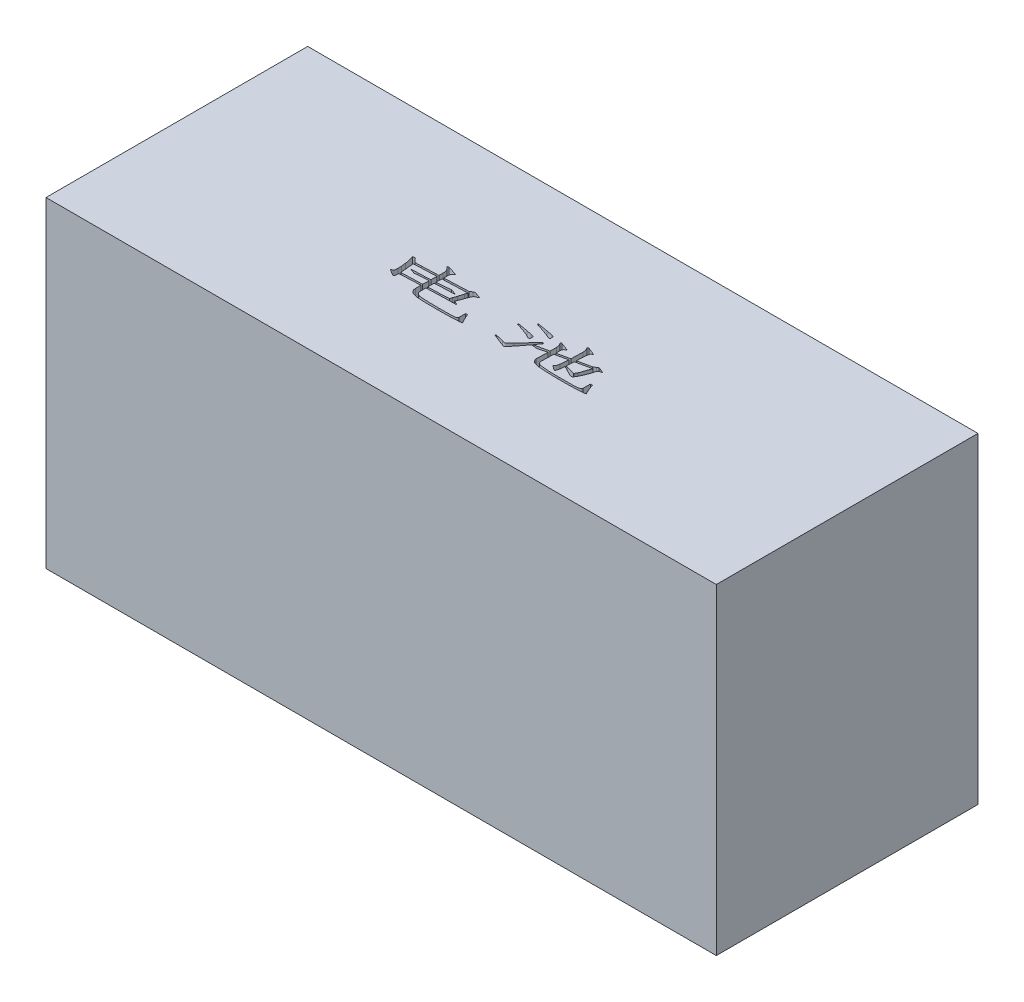
from build123d import *

# Parameters (mm, degrees)
SKETCH_1_W          = 73
SKETCH_1_H          = 28.5
EXTRUDE_1_DEPTH     = 35
CUT_EXTRUDE_1_DEPTH = 35


with BuildPart() as part:
    # 草图1 → 凸台-拉伸1 (new body)
    with BuildSketch(Plane(origin=(0, 0, 0), x_dir=(1, 0, 0), z_dir=(0, 1, 0))):
        Rectangle(SKETCH_1_W, SKETCH_1_H)
    extrude(amount=EXTRUDE_1_DEPTH)

    # 草图2 → 切除-拉伸1 (cut)
    with BuildSketch(Plane(origin=(0, 35, 0), x_dir=(1, 0, 0), z_dir=(0, 1, 0))):
        with BuildLine():
            Line((-10.707010031, 0.172814835), (-10.472085676, -0.074042186))
            Line((-10.472085676, -0.074042186), (-10.274450901, -0.290321751))
            Line((-10.274450901, -0.290321751), (-9.589068416, -0.270185378))
            Line((-9.589068416, -0.270185378), (-8.147453245, -0.22021734))
            Line((-8.147453245, -0.22021734), (-7.768591109, -0.200080967))
            Line((-7.768591109, -0.200080967), (-7.750692111, 0.26305562))
            add(Edge.make_bspline(
                [(-7.750692111, 0.26305562), (-7.750946332, 0.267032809), (-7.751740654, 0.279459649), (-7.753025791, 0.304847147), (-7.756515725, 0.343575859), (-7.759279045, 0.395227709), (-7.767268447, 0.458301711), (-7.784164071, 0.530582258), (-7.809571783, 0.610931523), (-7.840129127, 0.699888406), (-7.886137896, 0.793301523), (-7.953907193, 0.885469326), (-8.042517838, 0.97509931), (-8.111279609, 1.029956458), (-8.147453245, 1.058815262)],
                knots=[0, 0, 0, 0, 1.1956e-05, 3.7357e-05, 7.6252e-05, 0.000128591, 0.000192512, 0.000266691, 0.000350912, 0.000445278, 0.000548672, 0.000661899, 0.000786892, 0.000925638, 0.000925638, 0.000925638, 0.000925638], degree=3))
            Line((-8.147453245, 1.058815262), (-7.984870675, 1.128919672))
            Line((-7.984870675, 1.128919672), (-6.903472848, 0.786601326))
            add(Edge.make_bspline(
                [(-6.903472848, 0.786601326), (-6.931834624, 0.769628061), (-6.985546709, 0.737483762), (-7.057652231, 0.685317312), (-7.116950825, 0.632779809), (-7.167169144, 0.579718346), (-7.20418339, 0.516037304), (-7.228927556, 0.438914232), (-7.24315952, 0.346111903), (-7.244870519, 0.279020578), (-7.245791195, 0.242919246)],
                knots=[0, 0, 0, 0, 9.9134e-05, 0.000187742, 0.000266461, 0.000336696, 0.000405895, 0.000485373, 0.00057831, 0.000686576, 0.000686576, 0.000686576, 0.000686576], degree=3))
            Line((-7.245791195, 0.242919246), (-7.245791195, -0.179944594))
            Line((-7.245791195, -0.179944594), (-6.362773935, -0.149367138))
            Line((-6.362773935, -0.149367138), (-4.974855759, -0.094178559))
            Line((-4.974855759, -0.094178559), (-4.632537412, -0.074042186))
            Line((-4.632537412, -0.074042186), (-4.326017063, 0.101964633))
            add(Edge.make_bspline(
                [(-4.326017063, 0.101964633), (-4.312276138, 0.110511209), (-4.287564854, 0.125881123), (-4.252224004, 0.141964842), (-4.224372566, 0.153184803), (-4.198837208, 0.156140624), (-4.170498908, 0.150121653), (-4.132191241, 0.142367413), (-4.080207855, 0.129251154), (-4.041342455, 0.118467224), (-4.019496714, 0.112405715)],
                knots=[0, 0, 0, 0, 4.8476e-05, 8.7179e-05, 0.000116427, 0.00013817, 0.000163062, 0.000202701, 0.0002557, 0.000323726, 0.000323726, 0.000323726, 0.000323726], degree=3))
            Line((-4.019496714, 0.112405715), (-3.586937583, -0.023328357))
            add(Edge.make_bspline(
                [(-3.586937583, -0.023328357), (-3.565819521, -0.030856203), (-3.529671102, -0.043741843), (-3.486996326, -0.064583138), (-3.458745983, -0.07787574), (-3.448056382, -0.100791354), (-3.466420677, -0.119441528), (-3.482788373, -0.13020789), (-3.499581218, -0.136655745), (-3.513692103, -0.143487747), (-3.533355506, -0.151348532), (-3.557497147, -0.162287407), (-3.587223716, -0.174638146), (-3.62188487, -0.189637629), (-3.661925383, -0.205928125), (-3.720056634, -0.230970062), (-3.791534576, -0.266272744), (-3.865322001, -0.32259385), (-3.925569577, -0.388669809), (-3.952432657, -0.440525296), (-3.965799718, -0.46632857)],
                knots=[0, 0, 0, 0, 6.7038e-05, 0.000114752, 0.000143713, 0.000158116, 0.000182317, 0.000209831, 0.000219526, 0.000235883, 0.000256937, 0.000282987, 0.000315401, 0.000353495, 0.000396292, 0.00044506, 0.000543465, 0.000634454, 0.000722154, 0.000809015, 0.000809015, 0.000809015, 0.000809015], degree=3))
            Line((-3.965799718, -0.46632857), (-4.164180285, -0.989874276))
            Line((-4.164180285, -0.989874276), (-4.398358849, -1.629763473))
            Line((-4.398358849, -1.629763473), (-4.470700634, -1.790854459))
            Line((-4.470700634, -1.790854459), (-4.127636496, -1.926588531))
            add(Edge.make_bspline(
                [(-4.127636496, -1.926588531), (-4.114561488, -1.93255981), (-4.091925661, -1.942897458), (-4.065037692, -1.958708582), (-4.048465089, -1.972141284), (-4.045052084, -1.987979913), (-4.05662412, -1.998042665), (-4.073735953, -2.002781165), (-4.098187706, -2.00648772), (-4.116937191, -2.00689921), (-4.127636496, -2.007134025)],
                knots=[0, 0, 0, 0, 4.303e-05, 7.4495e-05, 9.4015e-05, 0.0001053, 0.000117441, 0.0001349, 0.000159054, 0.000191158, 0.000191158, 0.000191158, 0.000191158], degree=3))
            Line((-4.127636496, -2.007134025), (-4.416257847, -2.012354566))
            Line((-4.416257847, -2.012354566), (-6.00255659, -2.052627312))
            Line((-6.00255659, -2.052627312), (-6.903472848, -2.082458977))
            Line((-6.903472848, -2.082458977), (-7.282334983, -2.097374809))
            Line((-7.282334983, -2.097374809), (-7.282334983, -2.641056888))
            add(Edge.make_bspline(
                [(-7.282334983, -2.641056888), (-7.281712187, -2.669194737), (-7.280482796, -2.724738443), (-7.267858653, -2.806625852), (-7.248674378, -2.885635131), (-7.226268402, -2.949739619), (-7.201026783, -2.998484418), (-7.1752533, -3.033348861), (-7.142271328, -3.065219324), (-7.104392939, -3.096931214), (-7.059157535, -3.125863564), (-7.00730282, -3.152614307), (-6.949068204, -3.17750803), (-6.895039502, -3.198448984), (-6.842328724, -3.213364248), (-6.788977049, -3.222035959), (-6.723657429, -3.231964262), (-6.645526715, -3.240688539), (-6.554762063, -3.248755044), (-6.45107493, -3.256112904), (-6.334718312, -3.262747724), (-6.205686431, -3.268650719), (-6.064227124, -3.273805291), (-5.910092187, -3.278246564), (-5.743279982, -3.2819988), (-5.563533515, -3.284621093), (-5.371379933, -3.288192145), (-5.166522644, -3.288968703), (-4.94900521, -3.291099756), (-4.799595362, -3.290797023), (-4.722778197, -3.290641376)],
                knots=[0, 0, 0, 0, 8.4357e-05, 0.000166519, 0.000247917, 0.000328137, 0.000369506, 0.000412167, 0.000457519, 0.000506792, 0.000560162, 0.000618205, 0.000681663, 0.000750097, 0.000791894, 0.000845726, 0.000912068, 0.000990145, 0.0010815, 0.001185433, 0.00130197, 0.00143113, 0.001572927, 0.001726625, 0.001893724, 0.002073484, 0.002265922, 0.002470274, 0.00268805, 0.0029185, 0.0029185, 0.0029185, 0.0029185], degree=3))
            add(Edge.make_bspline(
                [(-4.722778197, -3.290641376), (-4.650685026, -3.290624858), (-4.510724837, -3.29059279), (-4.307371591, -3.29081756), (-4.116944412, -3.290045087), (-3.939691979, -3.288610468), (-3.775367134, -3.286370264), (-3.624212855, -3.28353304), (-3.486253, -3.279553938), (-3.36143854, -3.276106569), (-3.249809397, -3.271670735), (-3.151100145, -3.266536385), (-3.065564026, -3.260676959), (-2.992912065, -3.254240211), (-2.933530925, -3.246606071), (-2.886975776, -3.239999826), (-2.853641358, -3.231527096), (-2.817284475, -3.215765537), (-2.783066491, -3.18358237), (-2.744012413, -3.145175026), (-2.717490434, -3.103152074), (-2.708315662, -3.073602319), (-2.703920323, -3.059445979)],
                knots=[0, 0, 0, 0, 0.00021628, 0.000419881, 0.000610059, 0.000787564, 0.000951653, 0.001103078, 0.0012411, 0.001365703, 0.001477661, 0.001576244, 0.001662217, 0.00173487, 0.001794997, 0.001841834, 0.001875847, 0.001897883, 0.001959963, 0.002014304, 0.002062527, 0.002106875, 0.002106875, 0.002106875, 0.002106875], degree=3))
            Line((-2.703920323, -3.059445979), (-2.703920323, -2.782011502))
            Line((-2.703920323, -2.782011502), (-2.703920323, -2.34423183))
            Line((-2.703920323, -2.34423183), (-2.487640758, -2.334536539))
            Line((-2.487640758, -2.334536539), (-2.451842761, -2.455354779))
            Line((-2.451842761, -2.455354779), (-2.361601977, -2.661193262))
            Line((-2.361601977, -2.661193262), (-2.235563196, -2.933407197))
            Line((-2.235563196, -2.933407197), (-2.109524414, -3.164602595))
            Line((-2.109524414, -3.164602595), (-2.01928363, -3.330914123))
            add(Edge.make_bspline(
                [(-2.01928363, -3.330914123), (-2.014073457, -3.33847371), (-2.004876227, -3.351818229), (-1.995762729, -3.371061967), (-1.993834404, -3.387815847), (-2.001096318, -3.401383097), (-2.017089527, -3.409349998), (-2.04014304, -3.415349666), (-2.071745474, -3.422216676), (-2.096064627, -3.424893771), (-2.109524414, -3.426375448)],
                knots=[0, 0, 0, 0, 2.7514e-05, 4.8568e-05, 6.3503e-05, 7.6181e-05, 9.1914e-05, 0.000115272, 0.000148036, 0.000188646, 0.000188646, 0.000188646, 0.000188646], degree=3))
            Line((-2.109524414, -3.426375448), (-2.253462194, -3.442037072))
            add(Edge.make_bspline(
                [(-2.253462194, -3.442037072), (-2.270357116, -3.44388718), (-2.311287804, -3.448369368), (-2.38347487, -3.452841999), (-2.476903907, -3.459226388), (-2.59155602, -3.464655702), (-2.727259472, -3.471737826), (-2.883907607, -3.478026538), (-3.061631221, -3.485801095), (-3.32513051, -3.495498705), (-3.664195186, -3.50618358), (-4.068194747, -3.513951955), (-4.461987451, -3.519295523), (-4.721036677, -3.518000711), (-4.848816978, -3.517362024)],
                knots=[0, 0, 0, 0, 5.0982e-05, 0.000123512, 0.000216926, 0.000331933, 0.000467833, 0.000624593, 0.000802248, 0.001001514, 0.001415623, 0.001819925, 0.002213728, 0.002597066, 0.002597066, 0.002597066, 0.002597066], degree=3))
            add(Edge.make_bspline(
                [(-4.848816978, -3.517362024), (-4.922152784, -3.51707093), (-5.0650955, -3.516503543), (-5.273926122, -3.51638225), (-5.471798937, -3.513447035), (-5.658765019, -3.511987091), (-5.834749985, -3.507534253), (-5.999606612, -3.504597619), (-6.153451522, -3.498641284), (-6.296453409, -3.494242082), (-6.428403842, -3.48681911), (-6.549311942, -3.480939388), (-6.659109656, -3.472003494), (-6.758193042, -3.464703187), (-6.846329856, -3.454295129), (-6.923621979, -3.445572272), (-6.989647317, -3.433937062), (-7.061770439, -3.419610852), (-7.140493923, -3.399064891), (-7.226614829, -3.374427118), (-7.304992348, -3.350910983), (-7.374384328, -3.326093777), (-7.436173643, -3.303031191), (-7.488360757, -3.27762084), (-7.533648479, -3.254821903), (-7.580742603, -3.221956128), (-7.629386399, -3.178056176), (-7.679884895, -3.122509095), (-7.720782744, -3.061612237), (-7.752994601, -2.99691538), (-7.77537363, -2.928247077), (-7.793100337, -2.858340254), (-7.80266761, -2.785752331), (-7.804303476, -2.736791307), (-7.805134898, -2.711907091)],
                knots=[0, 0, 0, 0, 0.00022001, 0.000428833, 0.00062648, 0.000813687, 0.000989734, 0.001154596, 0.001308317, 0.001451605, 0.00158378, 0.001704785, 0.001814723, 0.001914252, 0.002002787, 0.002080953, 0.00214753, 0.002203841, 0.002301517, 0.002391461, 0.002472612, 0.002546911, 0.002612557, 0.002670273, 0.002720987, 0.002764429, 0.002842095, 0.002917098, 0.002989082, 0.003061458, 0.003133155, 0.003205327, 0.003277577, 0.003352249, 0.003352249, 0.003352249, 0.003352249], degree=3))
            Line((-7.805134898, -2.711907091), (-7.805134898, -2.117511182))
            Line((-7.805134898, -2.117511182), (-8.345833811, -2.133172806))
            Line((-8.345833811, -2.133172806), (-9.643511203, -2.188361384))
            Line((-9.643511203, -2.188361384), (-10.111868331, -2.208497758))
            Line((-10.111868331, -2.208497758), (-10.129767329, -2.435218406))
            Line((-10.129767329, -2.435218406), (-10.147666328, -2.565731936))
            add(Edge.make_bspline(
                [(-10.147666328, -2.565731936), (-10.148373549, -2.575534743), (-10.149822378, -2.595617007), (-10.162513707, -2.624623376), (-10.183825692, -2.650761677), (-10.210315824, -2.675829037), (-10.247628559, -2.693479544), (-10.294346757, -2.689193308), (-10.346832569, -2.6710928), (-10.381296365, -2.64892671), (-10.400489682, -2.636582139)],
                knots=[0, 0, 0, 0, 2.9324e-05, 6.0074e-05, 9.3041e-05, 0.000130016, 0.00016909, 0.000212371, 0.000266615, 0.000334792, 0.000334792, 0.000334792, 0.000334792], degree=3))
            Line((-10.400489682, -2.636582139), (-10.670466243, -2.46505007))
            Line((-10.670466243, -2.46505007), (-10.850947811, -2.354672912))
            add(Edge.make_bspline(
                [(-10.850947811, -2.354672912), (-10.861620335, -2.348544732), (-10.880685778, -2.337597325), (-10.905802657, -2.322213569), (-10.920983257, -2.310305381), (-10.933376673, -2.302136055), (-10.931412472, -2.292524412), (-10.925171985, -2.284321069), (-10.913878408, -2.273208669), (-10.896211537, -2.260492458), (-10.875091089, -2.24286569), (-10.84790809, -2.223504508), (-10.814773607, -2.202228696), (-10.791253181, -2.186420512), (-10.778606025, -2.177920302)],
                knots=[0, 0, 0, 0, 3.7095e-05, 6.6267e-05, 8.6555e-05, 9.8695e-05, 0.000103969, 0.000113693, 0.000129513, 0.000151295, 0.000178899, 0.000212018, 0.000251319, 0.000297032, 0.000297032, 0.000297032, 0.000297032], degree=3))
            add(Edge.make_bspline(
                [(-10.778606025, -2.177920302), (-10.764696744, -2.169096688), (-10.738104655, -2.152227497), (-10.70673111, -2.117273553), (-10.686963945, -2.07573381), (-10.676055125, -2.014991012), (-10.671670307, -1.941394984), (-10.662109879, -1.861728044), (-10.654580094, -1.797695649), (-10.65315095, -1.760537635), (-10.652567244, -1.745361171)],
                knots=[0, 0, 0, 0, 4.9245e-05, 9.4147e-05, 0.000138845, 0.00018536, 0.00027827, 0.000360053, 0.000426025, 0.000471573, 0.000471573, 0.000471573, 0.000471573], degree=3))
            Line((-10.652567244, -1.745361171), (-10.670466243, -1.36799062))
            Line((-10.670466243, -1.36799062), (-10.72490903, -0.894412951))
            add(Edge.make_bspline(
                [(-10.72490903, -0.894412951), (-10.725103309, -0.888443533), (-10.72556559, -0.874239464), (-10.727927251, -0.850106983), (-10.732010046, -0.820102303), (-10.735941368, -0.784155225), (-10.743478027, -0.742336375), (-10.750089791, -0.694139427), (-10.760543403, -0.640403629), (-10.773597049, -0.563730603), (-10.789527395, -0.472550117), (-10.809564087, -0.375569558), (-10.824973616, -0.297414883), (-10.838899721, -0.242849123), (-10.850646081, -0.203467756), (-10.86130471, -0.170470822), (-10.873726357, -0.131765678), (-10.889450857, -0.087767352), (-10.90861169, -0.038674079), (-10.928309666, 0.016862102), (-10.951451971, 0.077767616), (-10.968231832, 0.120133379), (-10.976986592, 0.14223738)],
                knots=[0, 0, 0, 0, 1.7915e-05, 4.2627e-05, 7.2691e-05, 0.000108768, 0.000151068, 0.000200115, 0.00025468, 0.00031525, 0.000433453, 0.000532325, 0.000612334, 0.000672388, 0.000701176, 0.000735611, 0.000776412, 0.000823118, 0.000875753, 0.000934501, 0.00099988, 0.001071204, 0.001071204, 0.001071204, 0.001071204], degree=3))
            Line((-10.976986592, 0.14223738), (-10.707010031, 0.172814835))
        make_face()
        with BuildLine():
            Line((-10.111868331, -2.001913483), (-7.805134898, -1.926588531))
            Line((-7.805134898, -1.926588531), (-7.786490108, -1.227036006))
            Line((-7.786490108, -1.227036006), (-8.273492026, -1.25686767))
            Line((-8.273492026, -1.25686767), (-8.832089938, -1.297140417))
            Line((-8.832089938, -1.297140417), (-9.336990854, -1.347854246))
            Line((-9.336990854, -1.347854246), (-9.463029635, -1.297140417))
            Line((-9.463029635, -1.297140417), (-9.769549984, -1.18676326))
            add(Edge.make_bspline(
                [(-9.769549984, -1.18676326), (-9.780119942, -1.183733244), (-9.798013612, -1.178603791), (-9.818957767, -1.170039314), (-9.832519852, -1.162080217), (-9.834339078, -1.149551264), (-9.821805188, -1.142814364), (-9.805796003, -1.137220671), (-9.781025213, -1.133030621), (-9.762317398, -1.131628385), (-9.751650986, -1.130828889)],
                knots=[0, 0, 0, 0, 3.2789e-05, 5.5509e-05, 6.926e-05, 7.6755e-05, 8.8405e-05, 0.000105864, 0.000130145, 0.000162352, 0.000162352, 0.000162352, 0.000162352], degree=3))
            Line((-9.751650986, -1.130828889), (-9.120711288, -1.106217766))
            Line((-9.120711288, -1.106217766), (-8.381631808, -1.080860852))
            Line((-8.381631808, -1.080860852), (-7.786490108, -1.050283396))
            Line((-7.786490108, -1.050283396), (-7.768591109, -0.396224159))
            Line((-7.768591109, -0.396224159), (-8.309290023, -0.421581073))
            Line((-8.309290023, -0.421581073), (-9.517472422, -0.46632857))
            Line((-9.517472422, -0.46632857), (-10.255806111, -0.502126567))
            Line((-10.255806111, -0.502126567), (-10.220008114, -0.894412951))
            Line((-10.220008114, -0.894412951), (-10.111868331, -2.001913483))
        make_face(mode=Mode.SUBTRACT)
        with BuildLine():
            Line((-7.282334983, -1.906452158), (-5.984657591, -1.866179411))
            Line((-5.984657591, -1.866179411), (-5.371616893, -1.835601956))
            Line((-5.371616893, -1.835601956), (-5.011399548, -1.815465582))
            Line((-5.011399548, -1.815465582), (-4.921158763, -1.573829102))
            Line((-4.921158763, -1.573829102), (-4.776475192, -1.166626886))
            Line((-4.776475192, -1.166626886), (-4.596739415, -0.552094604))
            Line((-4.596739415, -0.552094604), (-4.506498631, -0.28510121))
            Line((-4.506498631, -0.28510121), (-5.353717894, -0.310458124))
            Line((-5.353717894, -0.310458124), (-7.264435985, -0.381308327))
            Line((-7.264435985, -0.381308327), (-7.282334983, -1.020451732))
            add(Edge.make_bspline(
                [(-7.282334983, -1.020451732), (-7.193826599, -1.01459541), (-7.023243535, -1.003308464), (-6.776894793, -0.98522874), (-6.549848022, -0.967915726), (-6.342116616, -0.948622491), (-6.15330784, -0.931412778), (-5.983788856, -0.912629248), (-5.833327018, -0.894290648), (-5.739767666, -0.880651688), (-5.696036241, -0.874276577)],
                knots=[0, 0, 0, 0, 0.000266104, 0.000512866, 0.000741035, 0.000949202, 0.001138734, 0.001309794, 0.001460853, 0.00159343, 0.00159343, 0.00159343, 0.00159343], degree=3))
            Line((-5.696036241, -0.874276577), (-5.209034323, -1.040588105))
            add(Edge.make_bspline(
                [(-5.209034323, -1.040588105), (-5.195830636, -1.04559496), (-5.173082001, -1.054221272), (-5.147339182, -1.070392742), (-5.129344127, -1.082580681), (-5.126179873, -1.100047972), (-5.140080158, -1.110800748), (-5.160506194, -1.1162963), (-5.190769729, -1.120711124), (-5.214250265, -1.120979888), (-5.227679113, -1.121133598)],
                knots=[0, 0, 0, 0, 4.2109e-05, 7.255e-05, 9.2069e-05, 0.000104835, 0.000118546, 0.000139066, 0.000169231, 0.000209531, 0.000209531, 0.000209531, 0.000209531], degree=3))
            Line((-5.227679113, -1.121133598), (-5.479756675, -1.12635414))
            Line((-5.479756675, -1.12635414), (-6.074152584, -1.146490513))
            Line((-6.074152584, -1.146490513), (-6.651395286, -1.166626886))
            Line((-6.651395286, -1.166626886), (-7.282334983, -1.201679092))
            Line((-7.282334983, -1.201679092), (-7.282334983, -1.906452158))
        make_face(mode=Mode.SUBTRACT)
        with BuildLine():
            Line((4.193160435, -0.88471766), (4.409440001, -0.914549324))
            Line((4.409440001, -0.914549324), (4.301300218, -1.060724478))
            Line((4.301300218, -1.060724478), (3.904539084, -1.609627099))
            Line((3.904539084, -1.609627099), (5.43639504, -1.287445126))
            Line((5.43639504, -1.287445126), (5.43639504, -0.572230977))
            add(Edge.make_bspline(
                [(5.43639504, -0.572230977), (5.433082561, -0.534403858), (5.426849939, -0.463229944), (5.411877363, -0.363826219), (5.390837595, -0.279157838), (5.366410389, -0.205602734), (5.331798698, -0.140647118), (5.288035179, -0.078728734), (5.232061633, -0.018937375), (5.188931846, 0.017868449), (5.166418479, 0.037080763)],
                knots=[0, 0, 0, 0, 0.000113911, 0.00021433, 0.000301153, 0.000375452, 0.000446173, 0.000521079, 0.000602353, 0.000691106, 0.000691106, 0.000691106, 0.000691106], degree=3))
            Line((5.166418479, 0.037080763), (5.328255257, 0.097489883))
            Line((5.328255257, 0.097489883), (6.247816306, -0.264964836))
            add(Edge.make_bspline(
                [(6.247816306, -0.264964836), (6.220304983, -0.283115816), (6.169510223, -0.316628368), (6.102218033, -0.365993724), (6.050643486, -0.410516742), (6.013819606, -0.451011287), (5.989370241, -0.488852336), (5.969967291, -0.523117208), (5.957186538, -0.556897622), (5.947331675, -0.601402637), (5.941156998, -0.660322016), (5.933941134, -0.719320072), (5.928611546, -0.765413241), (5.929869615, -0.789680292), (5.930928744, -0.808316429), (5.938485568, -0.812362661), (5.941295956, -0.813867457)],
                knots=[0, 0, 0, 0, 9.8873e-05, 0.000182551, 0.000250184, 0.000303015, 0.000346038, 0.000385084, 0.00042096, 0.000453884, 0.0005216, 0.000598195, 0.000633374, 0.000658742, 0.000674117, 0.00068322, 0.00068322, 0.00068322, 0.00068322], degree=3))
            Line((5.941295956, -0.813867457), (5.941295956, -1.171101636))
            Line((5.941295956, -1.171101636), (7.293416135, -0.879497119))
            Line((7.293416135, -0.879497119), (7.329214132, 0.38387386))
            add(Edge.make_bspline(
                [(7.329214132, 0.38387386), (7.329172439, 0.392821906), (7.329054306, 0.418174703), (7.330394066, 0.45656499), (7.325252968, 0.504457796), (7.315269599, 0.559799189), (7.297442288, 0.631257576), (7.274843583, 0.714306074), (7.250237827, 0.798548595), (7.223831774, 0.872814854), (7.196907116, 0.931802172), (7.175905296, 0.964036235), (7.166631563, 0.978269768)],
                knots=[0, 0, 0, 0, 2.6848e-05, 7.6071e-05, 0.000115031, 0.000171064, 0.000244687, 0.000335869, 0.000429304, 0.000507868, 0.000572252, 0.000623163, 0.000623163, 0.000623163, 0.000623163], degree=3))
            Line((7.166631563, 0.978269768), (7.095035569, 1.068510552))
            Line((7.095035569, 1.068510552), (7.293416135, 1.093867467))
            Line((7.293416135, 1.093867467), (8.139889606, 0.751549121))
            add(Edge.make_bspline(
                [(8.139889606, 0.751549121), (8.110125115, 0.736750054), (8.056502761, 0.710088728), (7.986995118, 0.669583439), (7.937787346, 0.633019528), (7.904514236, 0.598469939), (7.888175409, 0.55917801), (7.877511074, 0.515187646), (7.870933235, 0.462366487), (7.870269741, 0.424413733), (7.869913046, 0.404010233)],
                knots=[0, 0, 0, 0, 9.973e-05, 0.000179669, 0.000240828, 0.000283625, 0.000321338, 0.000366739, 0.000419374, 0.00048057, 0.00048057, 0.00048057, 0.00048057], degree=3))
            Line((7.869913046, 0.404010233), (7.815470259, 0.066912428))
            Line((7.815470259, 0.066912428), (7.779672262, -0.773594711))
            Line((7.779672262, -0.773594711), (9.203388435, -0.46185382))
            Line((9.203388435, -0.46185382), (9.509908784, -0.290321751))
            add(Edge.make_bspline(
                [(9.509908784, -0.290321751), (9.524051592, -0.282317642), (9.550298748, -0.267463089), (9.587107364, -0.247554725), (9.617866653, -0.229832343), (9.643615777, -0.216368089), (9.663301246, -0.204816042), (9.677145593, -0.196730393), (9.685604761, -0.192006493), (9.689393725, -0.190132745), (9.690390352, -0.189639884)],
                knots=[0, 0, 0, 0, 4.8751e-05, 9.0475e-05, 0.000125536, 0.000155236, 0.000177623, 0.000193996, 0.000203341, 0.000206676, 0.000206676, 0.000206676, 0.000206676], degree=3))
            Line((9.690390352, -0.189639884), (9.816429133, -0.240353713))
            Line((9.816429133, -0.240353713), (10.15874748, -0.376087785))
            add(Edge.make_bspline(
                [(10.15874748, -0.376087785), (10.171417788, -0.380826441), (10.195069546, -0.389672124), (10.228011027, -0.40172583), (10.254809409, -0.414454282), (10.277125144, -0.423424423), (10.293686554, -0.431919515), (10.305242713, -0.438060252), (10.311508843, -0.443824349), (10.313700774, -0.453383776), (10.292518065, -0.459041502), (10.268184982, -0.470142493), (10.222097373, -0.484657607), (10.166614927, -0.499861606), (10.106727376, -0.518284187), (10.052559844, -0.541184998), (10.006332041, -0.566370641), (9.960255197, -0.603802956), (9.917275913, -0.651421048), (9.881720269, -0.701408545), (9.862412412, -0.749991147), (9.848488435, -0.800920857), (9.83162115, -0.867428164), (9.819179958, -0.934104837), (9.804948682, -0.996816168), (9.790164212, -1.05323726), (9.769160076, -1.116152069), (9.746790158, -1.187511357), (9.717724878, -1.265412805), (9.685950454, -1.351381672), (9.649405712, -1.44437661), (9.595414164, -1.575234277), (9.527029158, -1.736497559), (9.443499323, -1.919664201), (9.361103357, -2.086797346), (9.291833615, -2.214299639), (9.238152837, -2.306026396), (9.199372101, -2.363709453), (9.163206886, -2.413774671), (9.127160121, -2.454152956), (9.093168828, -2.486705568), (9.060093761, -2.510779971), (9.027755098, -2.525492579), (8.986957434, -2.533329826), (8.937925559, -2.530132865), (8.88053792, -2.520776243), (8.824079176, -2.502927164), (8.788742286, -2.484720485), (8.770829304, -2.475491152)],
                knots=[0, 0, 0, 0, 4.0589e-05, 7.5768e-05, 0.000105149, 0.000129533, 0.000147877, 0.000160923, 0.000168851, 0.000172654, 0.000187755, 0.000217258, 0.000264426, 0.000326507, 0.00039231, 0.000451458, 0.000502891, 0.000549597, 0.000628763, 0.000694954, 0.000732071, 0.000784933, 0.000853307, 0.000937848, 0.000988325, 0.001046214, 0.001112728, 0.001187255, 0.001270533, 0.001362099, 0.00146223, 0.001570256, 0.001786773, 0.00198768, 0.002174123, 0.002345662, 0.002422915, 0.002492829, 0.002554133, 0.002608017, 0.002654978, 0.002695119, 0.002730179, 0.002760602, 0.002818792, 0.002876296, 0.002935024, 0.002995401, 0.002995401, 0.002995401, 0.002995401], degree=3))
            Line((8.770829304, -2.475491152), (8.39271296, -2.274127419))
            Line((8.39271296, -2.274127419), (7.923610041, -2.04218623))
            Line((7.923610041, -2.04218623), (7.707330476, -1.941504363))
            Line((7.707330476, -1.941504363), (7.65363348, -2.409861491))
            Line((7.65363348, -2.409861491), (7.581291695, -2.717127632))
            add(Edge.make_bspline(
                [(7.581291695, -2.717127632), (7.577906659, -2.73392645), (7.571727484, -2.764591659), (7.554979244, -2.805052958), (7.530981965, -2.834286659), (7.500102704, -2.854008551), (7.458673258, -2.855088621), (7.411298165, -2.836052018), (7.354469485, -2.801417287), (7.315387088, -2.769898663), (7.293416135, -2.752179837)],
                knots=[0, 0, 0, 0, 5.1373e-05, 9.3778e-05, 0.000129778, 0.000163545, 0.000200157, 0.000248977, 0.000314847, 0.000399425, 0.000399425, 0.000399425, 0.000399425], degree=3))
            Line((7.293416135, -2.752179837), (7.040592781, -2.570952478))
            add(Edge.make_bspline(
                [(7.040592781, -2.570952478), (7.027358723, -2.561181576), (7.004223289, -2.544100342), (6.975426688, -2.520314757), (6.958617715, -2.503711723), (6.947376992, -2.488168567), (6.958622667, -2.472633293), (6.975270641, -2.456084368), (7.004057799, -2.4329451), (7.042987053, -2.407158119), (7.084003497, -2.372052233), (7.11993768, -2.326238384), (7.147063857, -2.270550845), (7.167692222, -2.208859017), (7.182005657, -2.145560576), (7.194609403, -2.086309539), (7.201632345, -2.03216454), (7.202680024, -1.997952198), (7.203175351, -1.98177711)],
                knots=[0, 0, 0, 0, 4.9521e-05, 8.6571e-05, 0.000110308, 0.000123649, 0.00013699, 0.000160727, 0.000197301, 0.000245938, 0.000301433, 0.000358275, 0.000419311, 0.000486292, 0.000553039, 0.000613884, 0.000667999, 0.000716527, 0.000716527, 0.000716527, 0.000716527], degree=3))
            Line((7.203175351, -1.98177711), (7.293416135, -1.086081393))
            Line((7.293416135, -1.086081393), (5.941295956, -1.388126993))
            Line((5.941295956, -1.388126993), (5.905497959, -2.651497971))
            add(Edge.make_bspline(
                [(5.905497959, -2.651497971), (5.905498341, -2.65448113), (5.90549939, -2.662684818), (5.905484173, -2.679092516), (5.905591575, -2.702955854), (5.904992956, -2.73507278), (5.908244542, -2.775793554), (5.91666219, -2.826190593), (5.932217561, -2.886257077), (5.944425851, -2.943950303), (5.967991934, -2.993583087), (6.004189153, -3.027890148), (6.053650637, -3.059761845), (6.118057026, -3.088873843), (6.19666323, -3.117434527), (6.290841712, -3.141533853), (6.399110966, -3.165902425), (6.499452685, -3.182272845), (6.588043441, -3.194966467), (6.662447624, -3.203626884), (6.742652783, -3.213057425), (6.829526845, -3.219901305), (6.922211684, -3.227640675), (7.020920827, -3.234250411), (7.125584463, -3.240220092), (7.236216652, -3.245438144), (7.353079533, -3.249601053), (7.475855699, -3.254635749), (7.60491168, -3.256979127), (7.739886404, -3.260314935), (7.880846228, -3.262504582), (8.028021376, -3.263687545), (8.181152248, -3.265707201), (8.285318268, -3.265426933), (8.338270173, -3.265284461)],
                knots=[0, 0, 0, 0, 8.949e-06, 2.4611e-05, 4.9222e-05, 8.0545e-05, 0.000120929, 0.000171566, 0.000233614, 0.00030707, 0.000348095, 0.000396088, 0.000454211, 0.000524272, 0.000607551, 0.000704882, 0.000815624, 0.000940438, 0.001009733, 0.001084107, 0.001165148, 0.00125198, 0.001345502, 0.001444175, 0.001548756, 0.001660002, 0.001776431, 0.001899568, 0.002028625, 0.002163646, 0.002304618, 0.002451547, 0.002605187, 0.002764041, 0.002764041, 0.002764041, 0.002764041], degree=3))
            add(Edge.make_bspline(
                [(8.338270173, -3.265284461), (8.394701589, -3.265601661), (8.505077932, -3.266222085), (8.666915764, -3.26597732), (8.821045962, -3.266060706), (8.967220932, -3.265963194), (9.105442421, -3.266250829), (9.235954868, -3.265275762), (9.358761162, -3.264507832), (9.47361879, -3.264049132), (9.580510544, -3.2623009), (9.679702171, -3.26089968), (9.771183978, -3.259315128), (9.854725951, -3.258131038), (9.930290622, -3.25568689), (9.998153926, -3.253402224), (10.058346617, -3.251543026), (10.126685183, -3.247244943), (10.203096075, -3.242945253), (10.286795964, -3.234944922), (10.362007874, -3.22810426), (10.428356266, -3.218919352), (10.486143545, -3.209642481), (10.535171485, -3.199151728), (10.575425219, -3.188371509), (10.616840145, -3.173078051), (10.658621123, -3.147701371), (10.697002525, -3.106913939), (10.724396167, -3.056539724), (10.732015279, -3.018751195), (10.735990182, -2.999036859)],
                knots=[0, 0, 0, 0, 0.000169296, 0.000331133, 0.000485512, 0.000631687, 0.000769659, 0.000900174, 0.001023232, 0.001138086, 0.001244745, 0.001343947, 0.001435691, 0.001519233, 0.001594591, 0.001662495, 0.001722946, 0.001775236, 0.001867907, 0.00195251, 0.002027462, 0.002094438, 0.002153412, 0.002203, 0.002244798, 0.002278317, 0.002335237, 0.002389577, 0.002444635, 0.002504688, 0.002504688, 0.002504688, 0.002504688], degree=3))
            Line((10.735990182, -2.999036859), (10.735990182, -2.309179624))
            Line((10.735990182, -2.309179624), (10.735990182, -2.203277217))
            Line((10.735990182, -2.203277217), (10.952269747, -2.193581926))
            Line((10.952269747, -2.193581926), (11.023865741, -2.374809286))
            Line((11.023865741, -2.374809286), (11.114106525, -2.651497971))
            Line((11.114106525, -2.651497971), (11.312487092, -3.089277643))
            add(Edge.make_bspline(
                [(11.312487092, -3.089277643), (11.320890149, -3.111532642), (11.336056047, -3.151698627), (11.360225692, -3.203707175), (11.379838075, -3.24329843), (11.405603751, -3.274183989), (11.429296972, -3.300593694), (11.450347861, -3.326437377), (11.445326245, -3.346431791), (11.430480775, -3.353156979), (11.410129051, -3.361407367), (11.379413648, -3.369105998), (11.34000412, -3.378023105), (11.29098971, -3.387647132), (11.23279807, -3.397242673), (11.190938788, -3.403103999), (11.168549312, -3.406239075)],
                knots=[0, 0, 0, 0, 7.1324e-05, 0.000128725, 0.000172116, 0.000203448, 0.000247859, 0.000283548, 0.000291334, 0.000305815, 0.000328251, 0.00035919, 0.000399717, 0.000449885, 0.000508859, 0.000576677, 0.000576677, 0.000576677, 0.000576677], degree=3))
            add(Edge.make_bspline(
                [(11.168549312, -3.406239075), (11.144195898, -3.409298536), (11.091567668, -3.415910094), (11.006553095, -3.424841943), (10.910064401, -3.432833887), (10.801916883, -3.440323657), (10.682574673, -3.446934197), (10.551289437, -3.452623525), (10.408875489, -3.459052318), (10.25445807, -3.46299088), (10.088894408, -3.467456984), (9.911414902, -3.472447995), (9.722705397, -3.474696773), (9.522101767, -3.478371143), (9.310283848, -3.479241043), (9.086796805, -3.480804642), (8.85187475, -3.482717057), (8.691278599, -3.482447787), (8.608992526, -3.482309818)],
                knots=[0, 0, 0, 0, 7.3633e-05, 0.000159123, 0.000256423, 0.000364075, 0.000484335, 0.000614985, 0.000758301, 0.000912, 0.001078371, 0.001255181, 0.001444635, 0.00164453, 0.001857085, 0.002080082, 0.002315011, 0.002561868, 0.002561868, 0.002561868, 0.002561868], degree=3))
            add(Edge.make_bspline(
                [(8.608992526, -3.482309818), (8.502095726, -3.482454654), (8.294017114, -3.482736581), (7.990461366, -3.480746095), (7.703821112, -3.475362433), (7.434076724, -3.468053789), (7.180984082, -3.458438648), (6.944796372, -3.44656371), (6.72545872, -3.432772704), (6.523548768, -3.415675535), (6.339895584, -3.396229059), (6.175200971, -3.372389416), (6.029613488, -3.345618316), (5.903594717, -3.313773251), (5.796635764, -3.279079711), (5.708466294, -3.241434816), (5.639671702, -3.198271821), (5.58960026, -3.150858935), (5.554803824, -3.102378845), (5.522212898, -3.060458557), (5.494737605, -3.021386713), (5.470927293, -2.98670341), (5.451246742, -2.956022314), (5.436080996, -2.929221919), (5.425624425, -2.906149635), (5.413329227, -2.872087679), (5.404976441, -2.828706278), (5.399863464, -2.779869848), (5.400671804, -2.745713556), (5.400616311, -2.727816602), (5.400597043, -2.721602382)],
                knots=[0, 0, 0, 0, 0.00032069, 0.000624236, 0.000910667, 0.001180747, 0.001433756, 0.001670473, 0.001890193, 0.002093029, 0.002278337, 0.002444138, 0.002592162, 0.002722217, 0.002833769, 0.002929257, 0.003009109, 0.003076101, 0.003134578, 0.003187828, 0.003235424, 0.00327783, 0.003314037, 0.003344751, 0.003370119, 0.003389935, 0.003453274, 0.003501957, 0.003537009, 0.003555654, 0.003555654, 0.003555654, 0.003555654], degree=3))
            Line((5.400597043, -2.721602382), (5.43639504, -1.513419982))
            add(Edge.make_bspline(
                [(5.43639504, -1.513419982), (5.35107908, -1.533607254), (5.183913106, -1.573161694), (4.939250905, -1.634585094), (4.706251424, -1.699077949), (4.555058995, -1.74366699), (4.481035995, -1.765497545)],
                knots=[0, 0, 0, 0, 0.000263015, 0.000515345, 0.00075671, 0.000988233, 0.000988233, 0.000988233, 0.000988233], degree=3))
            Line((4.481035995, -1.765497545), (3.832197299, -1.710308966))
            Line((3.832197299, -1.710308966), (3.345941173, -2.34423183))
            Line((3.345941173, -2.34423183), (2.787343261, -3.054225437))
            Line((2.787343261, -3.054225437), (2.679203478, -3.210095883))
            add(Edge.make_bspline(
                [(2.679203478, -3.210095883), (2.667874824, -3.223860087), (2.646364113, -3.24999539), (2.614512649, -3.285333409), (2.586031383, -3.31553735), (2.560741429, -3.340295861), (2.538665047, -3.359543299), (2.51990963, -3.373943691), (2.503583424, -3.381652391), (2.486947514, -3.385180715), (2.464486979, -3.378389871), (2.43030875, -3.367456136), (2.380108199, -3.350210886), (2.314974193, -3.325834683), (2.233853945, -3.295785547), (2.137873442, -3.257040698), (2.02575741, -3.213413933), (1.946063392, -3.181575164), (1.90358021, -3.164602595)],
                knots=[0, 0, 0, 0, 5.3474e-05, 0.000101535, 0.000142683, 0.000178019, 0.000207626, 0.000230601, 0.000248624, 0.000261498, 0.000280512, 0.000317306, 0.000370137, 0.00043927, 0.000526122, 0.000629575, 0.000749787, 0.00088703, 0.00088703, 0.00088703, 0.00088703], degree=3))
            Line((1.90358021, -3.164602595), (1.075005737, -2.837945872))
            Line((1.075005737, -2.837945872), (0.930322166, -2.772316211))
            Line((0.930322166, -2.772316211), (1.038461948, -2.70668655))
            Line((1.038461948, -2.70668655), (1.218943517, -2.746959296))
            Line((1.218943517, -2.746959296), (1.831984215, -2.893134451))
            add(Edge.make_bspline(
                [(1.831984215, -2.893134451), (1.857580681, -2.899386124), (1.906256282, -2.911274639), (1.975162779, -2.927507313), (2.035815044, -2.941665132), (2.088124615, -2.954111984), (2.132497047, -2.962545563), (2.168778922, -2.969958449), (2.196537916, -2.973442775), (2.220325806, -2.978889759), (2.246809173, -2.967010254), (2.28014942, -2.943708787), (2.326837025, -2.905846733), (2.383857312, -2.851655745), (2.45478876, -2.783816121), (2.536024676, -2.698979294), (2.63090223, -2.600177841), (2.697461175, -2.528546878), (2.732900474, -2.490406984)],
                knots=[0, 0, 0, 0, 7.9047e-05, 0.00015032, 0.000212369, 0.00026592, 0.000311554, 0.000347976, 0.000376667, 0.000396186, 0.000419064, 0.000460021, 0.000519423, 0.00059859, 0.000696163, 0.000813774, 0.000950922, 0.001107108, 0.001107108, 0.001107108, 0.001107108], degree=3))
            Line((2.732900474, -2.490406984), (4.030577866, -1.060724478))
            Line((4.030577866, -1.060724478), (4.193160435, -0.88471766))
        make_face()
        with BuildLine():
            Line((7.707330476, -1.810990833), (7.923610041, -1.875874702))
            add(Edge.make_bspline(
                [(7.923610041, -1.875874702), (7.957906202, -1.885854165), (8.024235939, -1.905154726), (8.120799346, -1.932623847), (8.21067715, -1.958875477), (8.294564558, -1.98260625), (8.371784473, -2.005057774), (8.442853503, -2.025304393), (8.507511259, -2.043129416), (8.565989614, -2.058825446), (8.618027873, -2.072698079), (8.663474068, -2.085982914), (8.703194745, -2.095480881), (8.736388029, -2.10306023), (8.762846904, -2.111168915), (8.783634375, -2.11343688), (8.797531942, -2.11789972), (8.804876383, -2.117609755), (8.807373093, -2.117511182)],
                knots=[0, 0, 0, 0, 0.000107155, 0.000207242, 0.000301182, 0.000388053, 0.000468778, 0.000542434, 0.000609741, 0.000669985, 0.000724079, 0.000771306, 0.000812004, 0.000846553, 0.000873505, 0.000894718, 0.000909198, 0.000916656, 0.000916656, 0.000916656, 0.000916656], degree=3))
            add(Edge.make_bspline(
                [(8.807373093, -2.117511182), (8.811039212, -2.11655965), (8.820462498, -2.11411386), (8.831252645, -2.098660966), (8.846776776, -2.079445373), (8.855901152, -2.062325614), (8.861070088, -2.052627312)],
                knots=[0, 0, 0, 0, 1.1087e-05, 2.8498e-05, 5.3557e-05, 8.6304e-05, 8.6304e-05, 8.6304e-05, 8.6304e-05], degree=3))
            Line((8.861070088, -2.052627312), (9.005753659, -1.80054975))
            add(Edge.make_bspline(
                [(9.005753659, -1.80054975), (9.010567969, -1.79139614), (9.021235248, -1.771114077), (9.036596469, -1.736633138), (9.053932562, -1.695766873), (9.071434139, -1.647430937), (9.091936217, -1.592795232), (9.112181873, -1.530497939), (9.13601556, -1.462035248), (9.167763883, -1.357534346), (9.214048325, -1.215347027), (9.274820472, -1.031905017), (9.344631883, -0.832758872), (9.393984215, -0.694761145), (9.419668, -0.622944807)],
                knots=[0, 0, 0, 0, 3.102e-05, 6.8732e-05, 0.000113193, 0.000164169, 0.000222917, 0.000288245, 0.000360648, 0.000440374, 0.00061585, 0.000809238, 0.001020098, 0.001248912, 0.001248912, 0.001248912, 0.001248912], degree=3))
            Line((9.419668, -0.622944807), (7.779672262, -0.980178985))
            Line((7.779672262, -0.980178985), (7.707330476, -1.810990833))
        make_face(mode=Mode.SUBTRACT)
        with BuildLine():
            Line((1.075005737, -0.502126567), (1.146601731, -0.426055823))
            Line((1.146601731, -0.426055823), (1.417324083, -0.471549111))
            Line((1.417324083, -0.471549111), (2.282442345, -0.632640097))
            Line((2.282442345, -0.632640097), (2.787343261, -0.728101423))
            add(Edge.make_bspline(
                [(2.787343261, -0.728101423), (2.808729913, -0.732539375), (2.849310302, -0.740960226), (2.906782634, -0.753473521), (2.957335069, -0.765822063), (3.001442948, -0.775413942), (3.038146481, -0.786626861), (3.068525794, -0.794880173), (3.092108769, -0.803313135), (3.114391254, -0.812481947), (3.135480595, -0.826663242), (3.153860442, -0.849304645), (3.163155673, -0.878106575), (3.164666766, -0.898584465), (3.165459604, -0.909328783)],
                knots=[0, 0, 0, 0, 6.5528e-05, 0.000124337, 0.000176436, 0.000221659, 0.000259665, 0.000291525, 0.000316057, 0.000334762, 0.000363723, 0.000391327, 0.000420575, 0.00045286, 0.00045286, 0.00045286, 0.00045286], degree=3))
            Line((3.165459604, -0.909328783), (3.147560606, -1.146490513))
            add(Edge.make_bspline(
                [(3.147560606, -1.146490513), (3.14576929, -1.15558347), (3.142401874, -1.172676921), (3.130690738, -1.19520221), (3.114776805, -1.213196432), (3.093172154, -1.225243734), (3.067875237, -1.233515266), (3.037713316, -1.235906815), (3.003568546, -1.234572856), (2.979709206, -1.229644748), (2.967079038, -1.227036006)],
                knots=[0, 0, 0, 0, 2.7675e-05, 5.2025e-05, 7.5252e-05, 9.8659e-05, 0.00012531, 0.000154548, 0.000188887, 0.00022751, 0.00022751, 0.00022751, 0.00022751], degree=3))
            add(Edge.make_bspline(
                [(2.967079038, -1.227036006), (2.952992283, -1.223514492), (2.920187497, -1.215313701), (2.86768024, -1.188078963), (2.802917037, -1.150885106), (2.75032289, -1.11217992), (2.705567016, -1.083038993), (2.670789504, -1.065353706), (2.627050874, -1.04386346), (2.57335679, -1.021549458), (2.51076521, -0.994957738), (2.438334987, -0.967188372), (2.357042011, -0.93546876), (2.265990748, -0.902046967), (2.165367534, -0.866528739), (2.055516184, -0.827669908), (1.93650542, -0.785471884), (1.80715916, -0.743152585), (1.669509124, -0.695217905), (1.521467054, -0.647362224), (1.364373695, -0.595846325), (1.25648376, -0.56054097), (1.201044518, -0.542399313)],
                knots=[0, 0, 0, 0, 4.3436e-05, 0.000101151, 0.000176362, 0.000267586, 0.000296758, 0.000336461, 0.000384493, 0.000442956, 0.000510823, 0.000588518, 0.000675635, 0.000772614, 0.000879471, 0.000995759, 0.001122183, 0.001258263, 0.001404015, 0.001559436, 0.001724998, 0.001899994, 0.001899994, 0.001899994, 0.001899994], degree=3))
            Line((1.201044518, -0.542399313), (1.075005737, -0.502126567))
        make_face()
        with BuildLine():
            Line((2.156403563, 0.56062647), (2.246644348, 0.645646713))
            Line((2.246644348, 0.645646713), (2.49872191, 0.600899216))
            Line((2.49872191, 0.600899216), (3.345941173, 0.449503521))
            Line((3.345941173, 0.449503521), (4.030577866, 0.32346474))
            add(Edge.make_bspline(
                [(4.030577866, 0.32346474), (4.052739703, 0.318678519), (4.093056308, 0.309971473), (4.147182629, 0.295677308), (4.188211222, 0.280075749), (4.218811662, 0.265288479), (4.239742507, 0.247630283), (4.254789594, 0.227734551), (4.2629913, 0.203727146), (4.264154765, 0.186792709), (4.264756429, 0.178035377)],
                knots=[0, 0, 0, 0, 6.8031e-05, 0.000123761, 0.000167668, 0.000199693, 0.000225094, 0.00024911, 0.000273642, 0.000299915, 0.000299915, 0.000299915, 0.000299915], degree=3))
            Line((4.264756429, 0.178035377), (4.264756429, -0.074042186))
            add(Edge.make_bspline(
                [(4.264756429, -0.074042186), (4.264570927, -0.081869593), (4.264222745, -0.096561382), (4.255137538, -0.115998643), (4.242493095, -0.131846036), (4.223328101, -0.141600632), (4.200384199, -0.148488723), (4.171965699, -0.148983536), (4.138961928, -0.146958893), (4.115559014, -0.14222728), (4.102919651, -0.139671847)],
                knots=[0, 0, 0, 0, 2.3228e-05, 4.3597e-05, 6.3173e-05, 8.2877e-05, 0.000106951, 0.000134586, 0.000167477, 0.0002061, 0.0002061, 0.0002061, 0.0002061], degree=3))
            Line((4.102919651, -0.139671847), (3.940337081, -0.063601103))
            Line((3.940337081, -0.063601103), (3.598018735, 0.087048801))
            add(Edge.make_bspline(
                [(3.598018735, 0.087048801), (3.588340927, 0.091069853), (3.565147137, 0.100706688), (3.523849385, 0.116328165), (3.470164665, 0.135315518), (3.404655056, 0.15972242), (3.326120494, 0.186194908), (3.235208785, 0.216498486), (3.132401264, 0.252129652), (3.02020052, 0.288425588), (2.906664462, 0.326181676), (2.798680154, 0.362207605), (2.699538328, 0.393912161), (2.60965545, 0.423334798), (2.528581176, 0.449342243), (2.456405402, 0.472199914), (2.39351868, 0.492910763), (2.354313145, 0.504527622), (2.33613934, 0.509912641)],
                knots=[0, 0, 0, 0, 3.1438e-05, 7.5345e-05, 0.000132436, 0.00020227, 0.000285053, 0.00038104, 0.000489765, 0.000611459, 0.000734804, 0.000848715, 0.00095296, 0.001047063, 0.001132442, 0.001208389, 0.001274192, 0.001331053, 0.001331053, 0.001331053, 0.001331053], degree=3))
            Line((2.33613934, 0.509912641), (2.156403563, 0.56062647))
        make_face()
    extrude(amount=-CUT_EXTRUDE_1_DEPTH, mode=Mode.SUBTRACT)


solid = part.part
